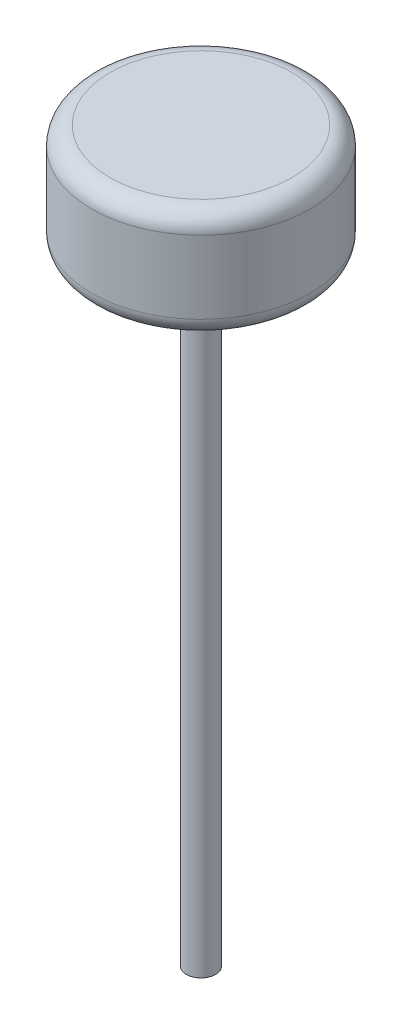
from build123d import *

# Parameters (mm, degrees)
SKETCH1_R           = 4
BOSS_EXTRUDE1_DEPTH = 170
SKETCH2_R           = 30
BOSS_EXTRUDE2_DEPTH = 30
FILLET1_R           = 5


with BuildPart() as part:
    # Sketch1 → Boss-Extrude1 (new body)
    with BuildSketch(Plane(origin=(0, 0, 0), x_dir=(1, 0, 0), z_dir=(0, 1, 0))):
        Circle(SKETCH1_R)
    extrude(amount=BOSS_EXTRUDE1_DEPTH)

    # Sketch2 → Boss-Extrude2 (add)
    with BuildSketch(Plane(origin=(0, 170, 0), x_dir=(1, 0, 0), z_dir=(0, 1, 0))):
        Circle(SKETCH2_R)
    extrude(amount=BOSS_EXTRUDE2_DEPTH)

    # Fillet1
    fillet1_edges = [part.edges().sort_by_distance(p)[0] for p in [
        (-30, 170, 0),
        (-30, 200, 0),
    ]]
    fillet(fillet1_edges, radius=FILLET1_R)


solid = part.part
